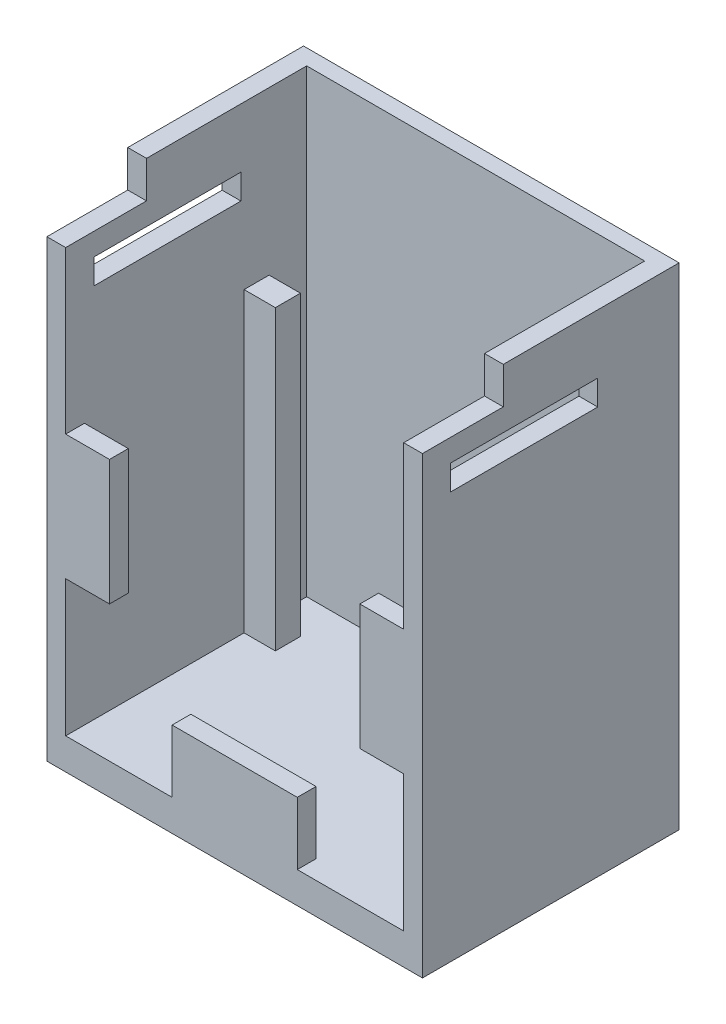
from build123d import *

# Parameters (mm, degrees)
SKETCH1_W                = 30.48
SKETCH1_H                = 40.64
INITIAL_BLOCK_DEPTH      = 19.05
INITIAL_BLOCK_DEPTH_BACK = 1.778
SKETCH2_W                = 27.432
SKETCH2_H                = 19.558
INITIAL_CUT_DEPTH        = 38.1
SKETCH20_W               = 5.08
SKETCH20_H               = 10.16
SKETCH20_W_2             = 10.16
SKETCH20_H_2             = 5.08
BOSS_EXTRUDE1_DEPTH      = 1.524
SKETCH21_W               = 2.032
SKETCH21_H               = 24.13
BOSS_EXTRUDE2_DEPTH      = 2.54
SKETCH27_W               = 11.938
SKETCH27_H               = 2.032
CUT_EXTRUDE6_DEPTH       = 1.524
SKETCH28_W               = 30.48
SKETCH28_H               = 1.778
CUT_EXTRUDE7_DEPTH       = 21.828
SKETCH29_W               = 30.48
SKETCH29_H               = 2
CUT_EXTRUDE8_DEPTH       = 5.81
BOSS_EXTRUDE3_DEPTH      = 0.99
SKETCH31_W               = 30.48
SKETCH31_H               = 2.99
CUT_EXTRUDE9_DEPTH       = 0.75


with BuildPart() as part:
    # Sketch1 → Initial Block (new body, two sides)
    with BuildSketch(Plane.XY) as initial_block_sk:
        with Locations((0, -5.08)):
            Rectangle(SKETCH1_W, SKETCH1_H)
    extrude(amount=INITIAL_BLOCK_DEPTH)
    extrude(initial_block_sk.sketch, amount=-INITIAL_BLOCK_DEPTH_BACK)

    # Sketch2 → Initial Cut (cut)
    with BuildSketch(Plane(origin=(0, 15.24, 0), x_dir=(1, 0, 0), z_dir=(0, 1, 0))):
        with Locations((0, -9.271)):
            Rectangle(SKETCH2_W, SKETCH2_H)
    extrude(amount=-INITIAL_CUT_DEPTH, mode=Mode.SUBTRACT)

    # Sketch20 → Boss-Extrude1 (add)
    with BuildSketch(Plane.XY.offset(19.05)):
        with Locations((-12.7, -6.731)):
            Rectangle(SKETCH20_W, SKETCH20_H)
        with Locations((12.7, -6.731)):
            Rectangle(SKETCH20_W, SKETCH20_H)
        with Locations((0, -20.32)):
            Rectangle(SKETCH20_W_2, SKETCH20_H_2)
    extrude(amount=-BOSS_EXTRUDE1_DEPTH)

    # Sketch21 → Boss-Extrude2 (add)
    with BuildSketch(Plane(origin=(-13.716, 0, 0), x_dir=(0, 0, -1), z_dir=(1, 0, 0))):
        with Locations((-3.556, -10.795)):
            Rectangle(SKETCH21_W, SKETCH21_H)
    boss_extrude2 = extrude(amount=BOSS_EXTRUDE2_DEPTH)

    # Mirror2: Boss-Extrude2 across plane
    add(boss_extrude2.mirror(Plane(origin=(0, 0, 0), x_dir=(0, 0, 1), z_dir=(1, 0, 0))))

    # Sketch27 → Cut-Extrude6 (cut)
    with BuildSketch(Plane(origin=(15.24, 0, 0), x_dir=(0, 0, -1), z_dir=(1, 0, 0))):
        with Locations((-10.795, 8.636)):
            Rectangle(SKETCH27_W, SKETCH27_H)
    cut_extrude6 = extrude(amount=-CUT_EXTRUDE6_DEPTH, mode=Mode.SUBTRACT)

    # Mirror6: Cut-Extrude6 across plane
    add(cut_extrude6.mirror(Plane(origin=(0, 0, 0), x_dir=(0, 0, 1), z_dir=(1, 0, 0))), mode=Mode.SUBTRACT)

    # Sketch28 → Cut-Extrude7 (cut, through all)
    with BuildSketch(Plane.XY.offset(19.05)):
        with Locations((0, 14.351)):
            Rectangle(SKETCH28_W, SKETCH28_H)
    extrude(amount=-CUT_EXTRUDE7_DEPTH, mode=Mode.SUBTRACT)

    # Sketch29 → Cut-Extrude8 (cut)
    with BuildSketch(Plane.XY.offset(19.05)):
        with Locations((0, 12.462)):
            Rectangle(SKETCH29_W, SKETCH29_H)
    extrude(amount=-CUT_EXTRUDE8_DEPTH, mode=Mode.SUBTRACT)

    # Sketch30 → Boss-Extrude3 (add)
    with BuildSketch(Plane(origin=(0, 13.462, 0), x_dir=(1, 0, 0), z_dir=(0, 1, 0))):
        Polygon((-15.24, -13.24), (-15.24, 1.778), (15.24, 1.778), (15.24, -13.24), (13.716, -13.24), (13.716, 0.508), (-13.716, 0.508), (-13.716, -13.24), align=None)
    extrude(amount=BOSS_EXTRUDE3_DEPTH)

    # Sketch31 → Cut-Extrude9 (cut)
    with BuildSketch(Plane.XY.offset(13.24)):
        with Locations((0, 12.957)):
            Rectangle(SKETCH31_W, SKETCH31_H)
    extrude(amount=-CUT_EXTRUDE9_DEPTH, mode=Mode.SUBTRACT)


solid = part.part
